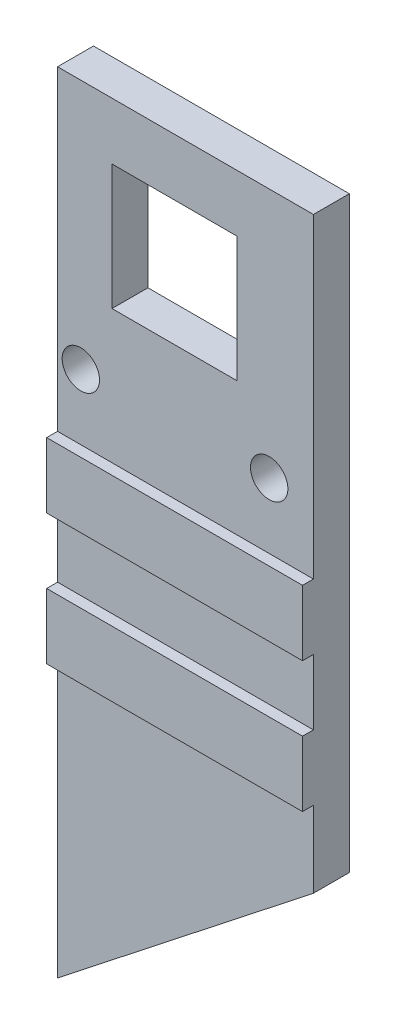
from build123d import *

# Parameters (mm, degrees)
SKETCH_1_W          = 30.50790567
SKETCH_1_H          = 76
SKETCH_1_R          = 1.716069694
SKETCH_1_W_2        = 11.5
SKETCH_1_H_2        = 11.5
SKETCH_1_W_3        = 24.50790567
SKETCH_1_H_3        = 19
EXTRUDE_1_DEPTH     = 3.3
SKETCH_2_W          = 30.50790567
SKETCH_2_H          = 6
EXTRUDE_2_DEPTH     = 1
EXTRUDE_3_DEPTH     = 3.3
CUT_EXTRUDE_1_DEPTH = 3.3
SKETCH_8_W          = 30.50790567
SKETCH_8_H          = 29
EXTRUDE_5_DEPTH     = 3.3
CUT_EXTRUDE_3_DEPTH = 3.3
SKETCH_12_W         = 4.466233575
SKETCH_12_H         = 76.29690536
SKETCH_12_W_2       = 3.912291759
SKETCH_12_H_2       = 55.852177881
CUT_EXTRUDE_6_DEPTH = 11.3


with BuildPart() as part:
    # 草圖1 → 填料-伸長1 (new body)
    with BuildSketch(Plane.XY):
        with Locations((0, -4.833822083)):
            Rectangle(SKETCH_1_W, SKETCH_1_H)
        with Locations((-8.65, 10.166177917)):
            Circle(SKETCH_1_R, mode=Mode.SUBTRACT)
        with Locations((-0.03771926, 22.181861337)):
            Rectangle(SKETCH_1_W_2, SKETCH_1_H_2, mode=Mode.SUBTRACT)
        with Locations((8.65, 10.166177917)):
            Circle(SKETCH_1_R, mode=Mode.SUBTRACT)
        with Locations((0, -30.333822083)):
            Rectangle(SKETCH_1_W_3, SKETCH_1_H_3, mode=Mode.SUBTRACT)
    extrude(amount=EXTRUDE_1_DEPTH)

    # 草圖2 → 填料-伸長2 (add)
    with BuildSketch(Plane.XY.offset(3.3)):
        with Locations((0, 1.166177917)):
            Rectangle(SKETCH_2_W, SKETCH_2_H)
        with Locations((0, -10.833822083)):
            Rectangle(SKETCH_2_W, SKETCH_2_H)
    extrude(amount=EXTRUDE_2_DEPTH)

    # 草圖3 → 填料-伸長3 (add)
    with BuildSketch(Plane.XY):
        Polygon((15.253952835, -42.833822083), (-15.253952835, -18.474060109), (15.253952835, -18.474060109), align=None)
    extrude(amount=EXTRUDE_3_DEPTH)

    # 草圖4 → 除料-伸長1 (cut)
    with BuildSketch(Plane.XY.offset(3.3)):
        Polygon((15.253952835, -42.833822083), (-15.253952835, -18.806748841), (-15.253952835, -42.833822083), align=None)
    extrude(amount=-CUT_EXTRUDE_1_DEPTH, mode=Mode.SUBTRACT)

    # 草圖8 → 填料-伸長5 (add)
    with BuildSketch(Plane.XY.offset(3.3)):
        with Locations((0, -28.333822083)):
            Rectangle(SKETCH_8_W, SKETCH_8_H)
    extrude(amount=-EXTRUDE_5_DEPTH)

    # 草圖9 → 除料-伸長3 (cut)
    with BuildSketch(Plane.XY.offset(3.3)):
        Polygon((-15.253952835, -42.833822083), (15.253952835, -18.833822083), (15.253952835, -42.833822083), align=None)
    extrude(amount=-CUT_EXTRUDE_3_DEPTH, mode=Mode.SUBTRACT)

    # 草圖12 → 除料-伸長6 (cut)
    with BuildSketch(Plane.XY.offset(4.3)):
        with Locations((-13.020836048, -4.982274763)):
            Rectangle(SKETCH_12_W, SKETCH_12_H)
        with Locations((14.66842662, 5.240088976)):
            Rectangle(SKETCH_12_W_2, SKETCH_12_H_2)
    extrude(amount=-CUT_EXTRUDE_6_DEPTH, mode=Mode.SUBTRACT)


solid = part.part
